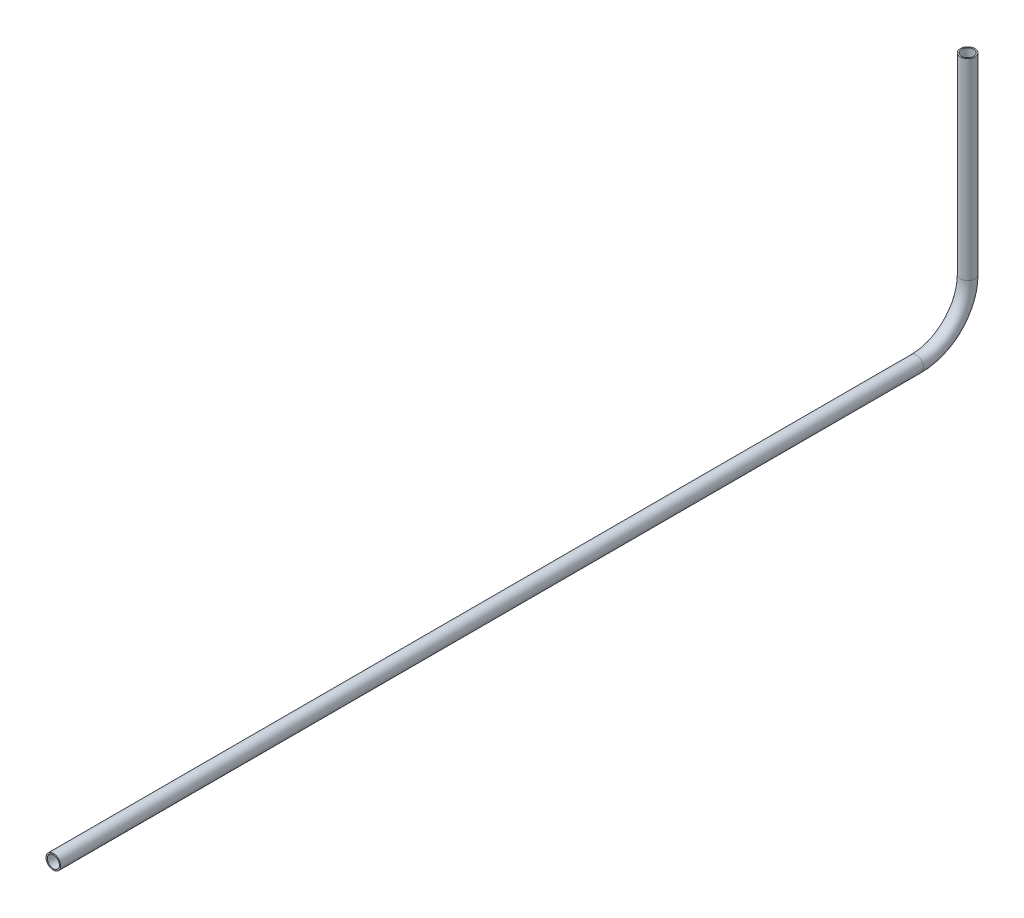
from build123d import *

# Parameters (mm, degrees)
SKETCH11_R                = 3.175
SKETCH11_R_2              = 2.6162
PIPE_0_5_SCH_40_1_DEPTH   = 374.034711
SKETCH11_ON_SEGMENT_2_R   = 3.175
SKETCH11_ON_SEGMENT_2_R_2 = 2.6162
PIPE_0_5_SCH_40_1_2_ANGLE = 90
SKETCH11_ON_SEGMENT_3_R   = 3.175
SKETCH11_ON_SEGMENT_3_R_2 = 2.6162
PIPE_0_5_SCH_40_1_3_DEPTH = 83.295965609


with BuildPart() as part:
    # Sketch11 → Pipe 0.5 SCH 40(1) (new body)
    with BuildSketch(Plane(origin=(0, 192.006959968, 242.917619127), x_dir=(0, 1, 0), z_dir=(0, 0, -1))):
        Circle(SKETCH11_R)
        Circle(SKETCH11_R_2, mode=Mode.SUBTRACT)
    extrude(amount=PIPE_0_5_SCH_40_1_DEPTH)


with BuildPart() as body_2:
    # Sketch11 on segment 2 (carried to the start of arc 2) → Pipe 0.5 SCH 40_1 2 (revolve)
    with BuildSketch(Plane(origin=(0, 192.006959968, -131.117091873), x_dir=(0, 1, 0), z_dir=(0, 0, -1))):
        Circle(SKETCH11_ON_SEGMENT_2_R)
        Circle(SKETCH11_ON_SEGMENT_2_R_2, mode=Mode.SUBTRACT)
    revolve(axis=Axis((0, 214.231959968, -131.117091873), (1, 0, 0)), revolution_arc=PIPE_0_5_SCH_40_1_2_ANGLE)


with BuildPart() as body_3:
    # Sketch11 on segment 3 (carried to segment 3) → Pipe 0.5 SCH 40_1 3 (new body)
    with BuildSketch(Plane(origin=(0, 214.231959968, -153.342091873), x_dir=(0, 0, 1), z_dir=(0, 1, 0))):
        Circle(SKETCH11_ON_SEGMENT_3_R)
        Circle(SKETCH11_ON_SEGMENT_3_R_2, mode=Mode.SUBTRACT)
    extrude(amount=PIPE_0_5_SCH_40_1_3_DEPTH)


solid = Compound([part.part, body_2.part, body_3.part])
